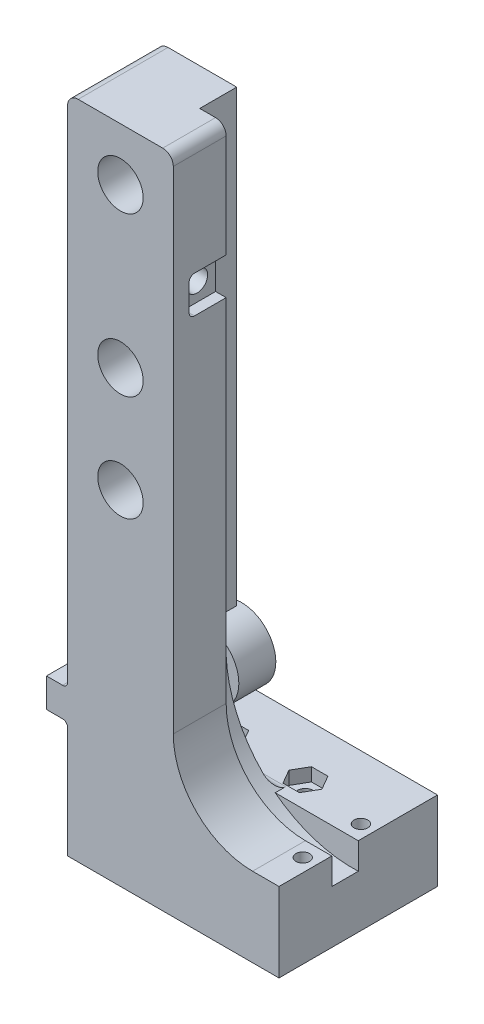
from build123d import *

# Parameters (mm, degrees)
BOSS_EXTRUDE1_DEPTH = 17
SKETCH3_W           = 40
SKETCH3_H           = 15
BOSS_EXTRUDE3_DEPTH = 13
FILLET1_R           = 15
SKETCH4_R           = 1.5000000000000004
SKETCH4_R_2         = 1.5000000000000007
CUT_EXTRUDE1_DEPTH  = 20
CUT_EXTRUDE2_DEPTH  = 2.5
SKETCH6_R           = 4.299999999999999
SKETCH6_R_2         = 4.299999999999998
SKETCH6_R_3         = 4.3
CUT_EXTRUDE3_DEPTH  = 12
SKETCH7_R           = 2.5000000000000004
SKETCH7_R_2         = 2.500000000000001
CUT_EXTRUDE4_DEPTH  = 12
CUT_EXTRUDE5_DEPTH  = 2
BOSS_EXTRUDE4_DEPTH = 23
BOSS_EXTRUDE5_DEPTH = 6
SKETCH11_W          = 6
SKETCH11_H          = 2
BOSS_EXTRUDE6_DEPTH = 4.419259302
SKETCH12_R          = 1.2500000000000002
CUT_EXTRUDE7_DEPTH  = 10
FILLET4_R           = 0.95
FILLET6_R           = 2
SKETCH13_R          = 6.500000000000007
SKETCH13_R_2        = 2.150000000000001
BOSS_EXTRUDE7_DEPTH = 1
SKETCH14_W          = 13.249650970727469
SKETCH14_H          = 1.5
CUT_EXTRUDE8_DEPTH  = 7
BOSS_EXTRUDE8_DEPTH = 10
SKETCH16_R          = 4.100000000000001
CUT_EXTRUDE9_DEPTH  = 6
CUT_EXTRUDE10_DEPTH = 5
SKETCH18_R          = 24.032057078793116
CUT_EXTRUDE11_DEPTH = 5
SKETCH20_R          = 1.3000000000000016
CUT_EXTRUDE12_DEPTH = 10
FILLET7_R           = 0.5
FILLET8_R           = 2
FILLET9_R           = 2
FILLET10_R          = 1
FILLET11_R          = 1
CUT_EXTRUDE15_DEPTH = 2
SKETCH24_R          = 2
CUT_EXTRUDE16_DEPTH = 5


with BuildPart() as part:
    # Sketch1 → Boss-Extrude1 (new body)
    with BuildSketch(Plane.XY):
        Polygon((0, 0), (1.531e-14, -125), (40.000000000000014, -125), (40.000000000000014, -110), (20.000000000000014, -110), (20.000000000000014, 0), align=None)
    extrude(amount=BOSS_EXTRUDE1_DEPTH)

    # Sketch3 → Boss-Extrude3 (add)
    with BuildSketch(Plane(origin=(0, 0, 0), x_dir=(-1, 0, 0), z_dir=(0, 0, -1))):
        with Locations((-20.000000000000014, -117.50000000000001)):
            Rectangle(SKETCH3_W, SKETCH3_H)
    extrude(amount=BOSS_EXTRUDE3_DEPTH)

    # Fillet1
    fillet1_edges = [part.edges().sort_by_distance(p)[0] for p in [
        (20.000000000000014, -110, 8.5),
    ]]
    fillet(fillet1_edges, radius=FILLET1_R)

    # Sketch4 → Cut-Extrude1 (cut)
    with BuildSketch(Plane.XZ.offset(125)):
        with Locations(Location((10.000000000000016, -2.999999999999999, 0), (0, 0, 270))):
            Circle(SKETCH4_R)
        with Locations(Location((25.000000000000014, -2.999999999999999, 0), (0, 0, 270))):
            Circle(SKETCH4_R_2)
    extrude(amount=-CUT_EXTRUDE1_DEPTH, mode=Mode.SUBTRACT)

    # Sketch5 → Cut-Extrude2 (cut)
    with BuildSketch(Plane(origin=(0, -110, 0), x_dir=(1, 0, 0), z_dir=(0, 1, 0))):
        Polygon((6.882308546376037, 3.0000000000000013), (8.441154273188026, 0.2999999999999986), (11.558845726812006, 0.2999999999999995), (13.117691453623996, 3.0000000000000018), (11.558845726812008, 5.7), (8.441154273188026, 5.699999999999998), align=None)
        Polygon((21.882308546376034, 2.999999999999999), (23.441154273188026, 0.2999999999999969), (26.558845726812, 0.29999999999999777), (28.117691453623994, 2.999999999999999), (26.558845726812, 5.6999999999999975), (23.441154273188022, 5.699999999999997), align=None)
    extrude(amount=-CUT_EXTRUDE2_DEPTH, mode=Mode.SUBTRACT)

    # Sketch6 → Cut-Extrude3 (cut)
    with BuildSketch(Plane.XY.offset(17)):
        with Locations((10.000000000000009, -10.000000000000002)):
            Circle(SKETCH6_R)
        with Locations((10.000000000000012, -40)):
            Circle(SKETCH6_R_2)
        with Locations((10.000000000000014, -60)):
            Circle(SKETCH6_R_3)
    extrude(amount=-CUT_EXTRUDE3_DEPTH, mode=Mode.SUBTRACT)

    # Sketch7 → Cut-Extrude4 (cut)
    with BuildSketch(Plane.XY.offset(5.000000000000001)):
        with Locations((10.000000000000009, -10.000000000000002)):
            Circle(SKETCH7_R)
        with Locations((10.000000000000012, -40)):
            Circle(SKETCH7_R_2)
        with Locations((10.000000000000014, -60)):
            Circle(SKETCH7_R_2)
    extrude(amount=-CUT_EXTRUDE4_DEPTH, mode=Mode.SUBTRACT)

    # Sketch8 → Cut-Extrude5 (cut)
    with BuildSketch(Plane(origin=(0, 0, 0), x_dir=(-1, 0, 0), z_dir=(0, 0, -1))):
        Polygon((-1.531e-14, -110), (-3.06e-15, -84.99999999999999), (-40.000000000000014, -84.99999999999999), (-40.000000000000014, -110), align=None)
    extrude(amount=-CUT_EXTRUDE5_DEPTH, mode=Mode.SUBTRACT)

    # Sketch9 → Boss-Extrude4 (add)
    with BuildSketch(Plane.XY.offset(17)):
        Polygon((-2.69e-15, -103.00000000000001), (-4, -103.00000000000001), (-4, -97.5), (0, -97.5), align=None)
    extrude(amount=-BOSS_EXTRUDE4_DEPTH)

    # Sketch10 → Boss-Extrude5 (add)
    with BuildSketch(Plane(origin=(0, 0, -5.999999999999998), x_dir=(-1, 0, 0), z_dir=(0, 0, -1))):
        with BuildLine():
            Line((4, -103.00000000000001), (-9.9, -103.00000000000001))
            ThreePointArc((-9.9, -103.00000000000001), (-15.308326913195994, -92.894448724536), (-3.8999999999999964, -94))
            Line((-3.8999999999999964, -94), (-0.41925930159213404, -94))
            Line((-0.41925930159213404, -94), (-0.41925930159213404, -96))
            Line((-0.41925930159213404, -96), (-5.931373033403113, -96))
            ThreePointArc((-5.931373033403113, -96), (-13.892119004323362, -96.24903017049799), (-6.025237793012059, -97.49308501111332))
            Line((-6.025237793012059, -97.49308501111332), (4, -97.5))
            Line((4, -97.5), (4, -103.00000000000001))
        make_face()
    extrude(amount=-BOSS_EXTRUDE5_DEPTH)

    # Sketch11 → Boss-Extrude6 (add)
    with BuildSketch(Plane.ZY.offset(-0.41925930159213404)):
        with Locations((-2.9999999999999982, -95)):
            Rectangle(SKETCH11_W, SKETCH11_H)
    extrude(amount=BOSS_EXTRUDE6_DEPTH)

    # Sketch12 → Cut-Extrude7 (cut)
    with BuildSketch(Plane(origin=(0, -94, 0), x_dir=(1, 0, 0), z_dir=(0, 1, 0))):
        with Locations((-0.05000000000000317, 2.9999999999999982)):
            Circle(SKETCH12_R)
    extrude(amount=-CUT_EXTRUDE7_DEPTH, mode=Mode.SUBTRACT)

    # Fillet4
    fillet4_edges = [part.edges().sort_by_distance(p)[0] for p in [
        (0, -97.5, 9.5),
        (-2.69e-15, -103.00000000000001, 9.5),
    ]]
    fillet(fillet4_edges, radius=FILLET4_R)

    # Fillet6
    fillet6_edges = [part.edges().sort_by_distance(p)[0] for p in [
        (20.000000000000014, 0, 8.5),
        (0, 0, 8.5),
    ]]
    fillet(fillet6_edges, radius=FILLET6_R)

    # Sketch13 → Boss-Extrude7 (add)
    with BuildSketch(Plane.XY):
        with Locations(Location((9.9, -96.5, 0), (0, 0, 175.588274214))):
            Circle(SKETCH13_R)
        with Locations((9.9, -96.5)):
            Circle(SKETCH13_R_2, mode=Mode.SUBTRACT)
    extrude(amount=BOSS_EXTRUDE7_DEPTH)

    # Sketch14 → Cut-Extrude8 (cut)
    with BuildSketch(Plane(origin=(0, 0, -5.999999999999998), x_dir=(-1, 0, 0), z_dir=(0, 0, -1))):
        with Locations((-2.6248254853637345, -96.75)):
            Rectangle(SKETCH14_W, SKETCH14_H)
    extrude(amount=-CUT_EXTRUDE8_DEPTH, mode=Mode.SUBTRACT)

    # Sketch15 → Boss-Extrude8 (add)
    with BuildSketch(Plane.XY):
        Polygon((0, -97.5), (2.5, -97.5), (2.5000000000000013, -103.00000000000001), (0, -103.00000000000001), align=None)
    extrude(amount=BOSS_EXTRUDE8_DEPTH)

    # Sketch16 → Cut-Extrude9 (cut)
    with BuildSketch(Plane(origin=(0, 0, -5.999999999999998), x_dir=(-1, 0, 0), z_dir=(0, 0, -1))):
        with Locations((-9.9, -96.5)):
            Circle(SKETCH16_R)
    extrude(amount=-CUT_EXTRUDE9_DEPTH, mode=Mode.SUBTRACT)

    # Sketch17 → Cut-Extrude10 (cut)
    with BuildSketch(Plane(origin=(20.000000000000014, 0, 0), x_dir=(0, 0, -1), z_dir=(1, 0, 0))):
        Polygon((0, 0), (-7, -8.6e-16), (-6.9999999999999885, -89.75912634068962), (0, -89.75912634068962), align=None)
    extrude(amount=-CUT_EXTRUDE10_DEPTH, mode=Mode.SUBTRACT)

    # Sketch18 → Cut-Extrude11 (cut)
    with BuildSketch(Plane(origin=(0, 0, 2), x_dir=(-1, 0, 0), z_dir=(0, 0, -1))):
        with Locations((-39.000000000000014, -91)):
            Circle(SKETCH18_R)
    extrude(amount=-CUT_EXTRUDE11_DEPTH, mode=Mode.SUBTRACT)

    # Sketch20 → Cut-Extrude12 (cut)
    with BuildSketch(Plane(origin=(0, -110, 0), x_dir=(1, 0, 0), z_dir=(0, 1, 0))):
        with Locations(Location((37.50000000000002, -9.999999999999998, 0), (0, 0, 270))):
            Circle(SKETCH20_R)
        with Locations(Location((37.50000000000002, 0.9999999999999974, 0), (0, 0, 90))):
            Circle(SKETCH20_R)
    extrude(amount=-CUT_EXTRUDE12_DEPTH, mode=Mode.SUBTRACT)

    # Fillet7
    fillet7_edges = [part.edges().sort_by_distance(p)[0] for p in [
        (2.500000000000001, -100.25, 2),
        (2.500000000000001, -100.25, 0),
    ]]
    fillet(fillet7_edges, radius=FILLET7_R)

    # Fillet8
    fillet8_edges = [part.edges().sort_by_distance(p)[0] for p in [
        (12.142354869960766, -110, 2),
    ]]
    fillet(fillet8_edges, radius=FILLET8_R)

    # Fillet9
    fillet9_edges = [part.edges().sort_by_distance(p)[0] for p in [
        (3.899999999999995, -94, -2.9999999999999982),
    ]]
    fillet(fillet9_edges, radius=FILLET9_R)

    # Fillet10
    fillet10_edges = [part.edges().sort_by_distance(p)[0] for p in [
        (1.025000000000007, -103.00000000000001, 2),
    ]]
    fillet(fillet10_edges, radius=FILLET10_R)

    # Fillet11
    fillet11_edges = [part.edges().sort_by_distance(p)[0] for p in [
        (1.0250000000000057, -97.5, 2),
    ]]
    fillet(fillet11_edges, radius=FILLET11_R)

    # Sketch23 → Cut-Extrude15 (cut)
    with BuildSketch(Plane(origin=(20.000000000000014, 0, 0), x_dir=(0, 0, -1), z_dir=(1, 0, 0))):
        with BuildLine():
            Line((-7, -21.5), (-7, -28.499999999999996))
            Line((-7, -28.499999999999996), (-12.999999999999993, -28.499999999999996))
            ThreePointArc((-12.999999999999993, -28.499999999999996), (-13.707106781186548, -28.207106781186543), (-14, -27.49999999999999))
            Line((-14, -27.49999999999999), (-14, -22.500000000000007))
            ThreePointArc((-14, -22.500000000000007), (-13.707106781186548, -21.79289321881345), (-12.999999999999993, -21.5))
            Line((-12.999999999999993, -21.5), (-7, -21.5))
        make_face()
    extrude(amount=-CUT_EXTRUDE15_DEPTH, mode=Mode.SUBTRACT)

    # Sketch24 → Cut-Extrude16 (cut)
    with BuildSketch(Plane(origin=(18.000000000000014, 0, 0), x_dir=(0, 0, -1), z_dir=(1, 0, 0))):
        with Locations((-10.5, -24.999999999999996)):
            Circle(SKETCH24_R)
    extrude(amount=-CUT_EXTRUDE16_DEPTH, mode=Mode.SUBTRACT)


solid = part.part
